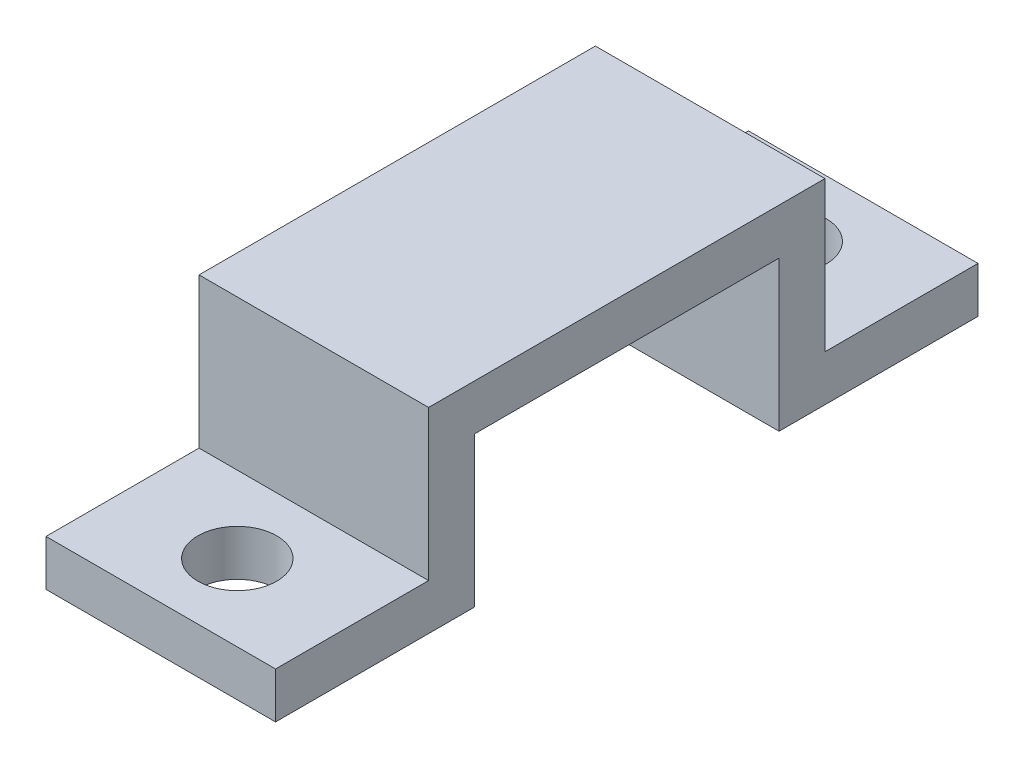
from build123d import *

# Parameters (mm, degrees)
SALIENTE_EXTRUIR1_DEPTH = 15
CROQUIS5_R              = 2.575
CORTAR_EXTRUIR1_DEPTH   = 4


with BuildPart() as part:
    # Croquis2 → Saliente-Extruir1 (new body)
    with BuildSketch(Plane(origin=(0, 0, 0), x_dir=(0, 0, -1), z_dir=(1, 0, 0))):
        Polygon((-22.95, -12.8), (-9.95, -12.8), (-9.95, -3), (9.95, -3), (9.95, -12.8), (22.95, -12.8), (22.95, -9.8), (12.95, -9.8), (12.95, 0), (-12.95, 0), (-12.95, -9.8), (-22.95, -9.8), align=None)
    extrude(amount=SALIENTE_EXTRUIR1_DEPTH)

    # Croquis5 → Cortar-Extruir1 (cut, through all)
    with BuildSketch(Plane(origin=(0, -9.8, 0), x_dir=(1, 0, 0), z_dir=(0, 1, 0))):
        with Locations((7.5, -17.95)):
            Circle(CROQUIS5_R)
    cortar_extruir1 = extrude(amount=-CORTAR_EXTRUIR1_DEPTH, mode=Mode.SUBTRACT)

    # Simetría1: Cortar-Extruir1 across plane
    add(cortar_extruir1.mirror(Plane.XY), mode=Mode.SUBTRACT)


solid = part.part
